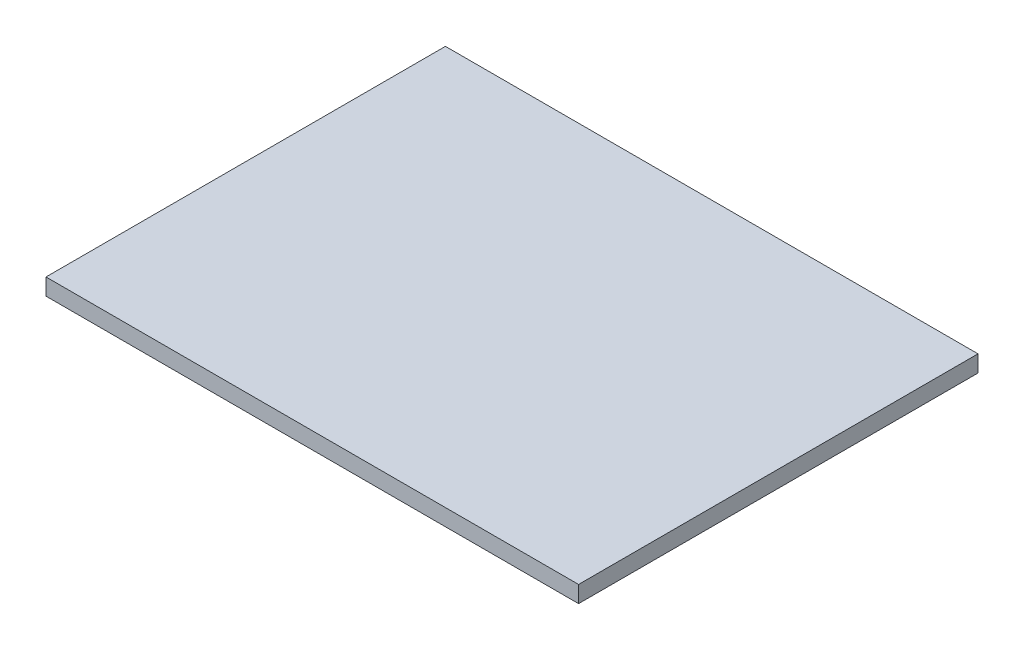
from build123d import *

# Parameters (mm, degrees)
SKETCH1_W           = 406.4
SKETCH1_H           = 304.8
BOSS_EXTRUDE1_DEPTH = 12.7


with BuildPart() as part:
    # Sketch1 → Boss-Extrude1 (new body)
    with BuildSketch(Plane(origin=(0, 0, 0), x_dir=(1, 0, 0), z_dir=(0, 1, 0))):
        Rectangle(SKETCH1_W, SKETCH1_H)
    extrude(amount=BOSS_EXTRUDE1_DEPTH)


solid = part.part
